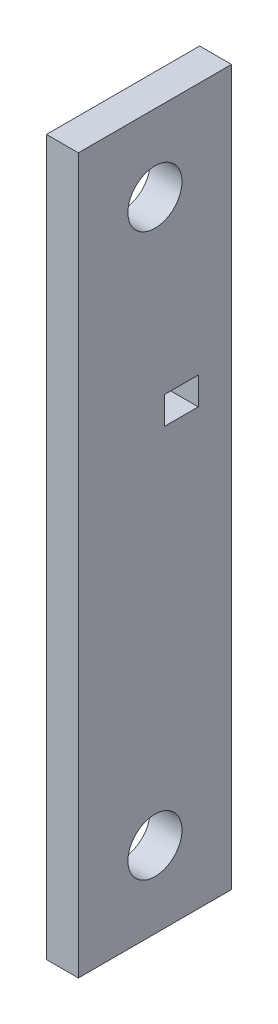
from build123d import *

# Parameters (mm, degrees)
SKETCH1_W               = 7.9375
SKETCH1_H               = 177.8
EXTRUDE_THIN1_DEPTH     = 19.05
SKETCH2_R               = 6.731
CUT_EXTRUDE1_DEPTH      = 4.96875
CUT_EXTRUDE1_DEPTH_BACK = 5.08
SKETCH3_W               = 8.382
SKETCH3_H               = 6.858
CUT_EXTRUDE2_DEPTH      = 4.96875
CUT_EXTRUDE2_DEPTH_BACK = 4.96875


with BuildPart() as part:
    # Sketch1 → Extrude-Thin1 (new body, symmetric)
    with BuildSketch(Plane.XY):
        Rectangle(SKETCH1_W, SKETCH1_H)
    extrude(amount=EXTRUDE_THIN1_DEPTH, both=True)

    # Sketch2 → Cut-Extrude1 (cut, two sides)
    with BuildSketch(Plane(origin=(0, 0, 0), x_dir=(0, 0, -1), z_dir=(1, 0, 0))) as cut_extrude1_sk:
        with Locations((0, 69.85)):
            Circle(SKETCH2_R)
        with Locations((0, -69.85)):
            Circle(SKETCH2_R)
    extrude(amount=CUT_EXTRUDE1_DEPTH, mode=Mode.SUBTRACT)
    extrude(cut_extrude1_sk.sketch, amount=-CUT_EXTRUDE1_DEPTH_BACK, mode=Mode.SUBTRACT)

    # Sketch3 → Cut-Extrude2 (cut, two sides)
    with BuildSketch(Plane(origin=(0, 0, 0), x_dir=(0, 0, -1), z_dir=(1, 0, 0))) as cut_extrude2_sk:
        with Locations((6.58622, 22.6822)):
            Rectangle(SKETCH3_W, SKETCH3_H)
    extrude(amount=CUT_EXTRUDE2_DEPTH, mode=Mode.SUBTRACT)
    extrude(cut_extrude2_sk.sketch, amount=-CUT_EXTRUDE2_DEPTH_BACK, mode=Mode.SUBTRACT)


solid = part.part
